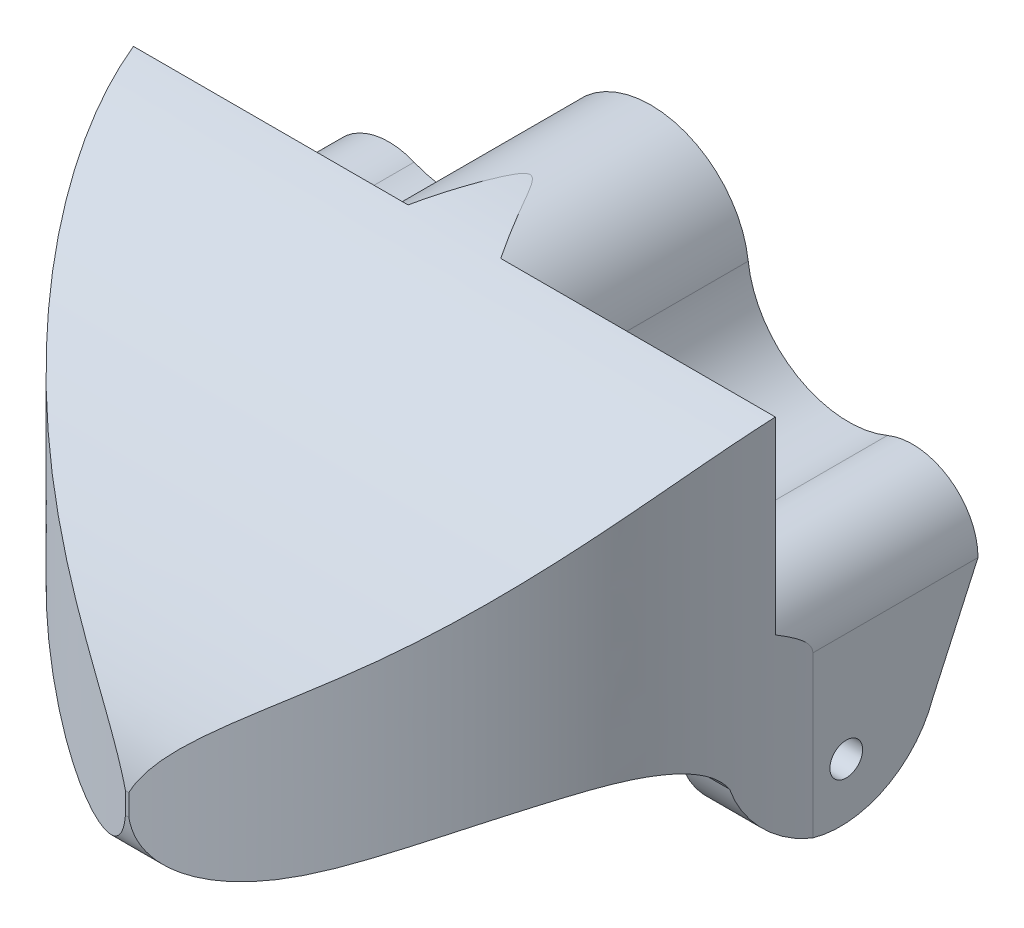
from build123d import *

# Parameters (mm, degrees)
SKETCH1_W                = 50
SKETCH1_H                = 35
BOSS_EXTRUDE1_DEPTH      = 40
CUT_EXTRUDE3_DEPTH       = 15
CUT_EXTRUDE6_DEPTH       = 51.311529494
CUT_EXTRUDE6_DEPTH_BACK  = 51.311529494
CUT_EXTRUDE8_DEPTH       = 51.292408862
CUT_EXTRUDE8_DEPTH_BACK  = 51.292408862
SKETCH6_W                = 40
SKETCH6_H                = 12.54309885
CUT_EXTRUDE9_DEPTH       = 25
SKETCH7_R                = 1.25
CUT_EXTRUDE10_DEPTH      = 51.292408862
CUT_EXTRUDE10_DEPTH_BACK = 51.292408862


with BuildPart() as part:
    # Sketch1 → Boss-Extrude1 (new body)
    with BuildSketch(Plane.XY):
        Rectangle(SKETCH1_W, SKETCH1_H)
    extrude(amount=BOSS_EXTRUDE1_DEPTH)

    # Sketch3 → Cut-Extrude3 (cut)
    with BuildSketch(Plane.XY):
        with BuildLine():
            ThreePointArc((18.080023646, 4.616675297), (22.774898037, 4.159319762), (25, 0))
            Line((25, 0), (25, 17.5))
            Line((25, 17.5), (20.265083079, 17.5))
            ThreePointArc((20.265083079, 17.5), (22.164558634, 14.89755515), (22.836723839, 11.746536186))
            ThreePointArc((22.836723839, 11.746536186), (21.538401387, 7.461063254), (18.080023646, 4.616675297))
        make_face()
        with BuildLine():
            ThreePointArc((9.964651512, 17.5), (7.890776302, 14.474095131), (7.447285057, 10.832615462))
            ThreePointArc((7.447285057, 10.832615462), (11.217729841, 5.080248753), (18.080023646, 4.616675297))
            ThreePointArc((18.080023646, 4.616675297), (21.538401387, 7.461063254), (22.836723839, 11.746536186))
            ThreePointArc((22.836723839, 11.746536186), (22.164558634, 14.89755515), (20.265083079, 17.5))
            Line((20.265083079, 17.5), (9.964651512, 17.5))
        make_face()
        with BuildLine():
            ThreePointArc((20.265083079, 17.5), (15.114867296, 19.46839273), (9.964651512, 17.5))
            Line((9.964651512, 17.5), (20.265083079, 17.5))
        make_face()
        with BuildLine():
            ThreePointArc((-7.393010752, 11.746536186), (-7.406591271, 11.28877073), (-7.447285061, 10.832615429))
            ThreePointArc((-7.447285061, 10.832615429), (-1.7e-08, 17.444952642), (7.447285057, 10.832615462))
            ThreePointArc((7.447285057, 10.832615462), (7.890776302, 14.474095131), (9.964651512, 17.5))
            Line((9.964651512, 17.5), (-9.964651512, 17.5))
            ThreePointArc((-9.964651512, 17.5), (-8.065175957, 14.89755515), (-7.393010752, 11.746536186))
        make_face()
        with BuildLine():
            ThreePointArc((-20.265083079, 17.5), (-22.728002657, 10.455320307), (-18.080023619, 4.616675286))
            ThreePointArc((-18.080023619, 4.616675286), (-11.217729842, 5.080248753), (-7.447285061, 10.832615429))
            ThreePointArc((-7.447285061, 10.832615429), (-7.406591271, 11.28877073), (-7.393010752, 11.746536186))
            ThreePointArc((-7.393010752, 11.746536186), (-8.065175957, 14.89755515), (-9.964651512, 17.5))
            Line((-9.964651512, 17.5), (-20.265083079, 17.5))
        make_face()
        with BuildLine():
            ThreePointArc((-9.964651512, 17.5), (-15.114867296, 19.46839273), (-20.265083079, 17.5))
            Line((-20.265083079, 17.5), (-9.964651512, 17.5))
        make_face()
        with BuildLine():
            Line((-25, 17.5), (-25, 2.5e-08))
            ThreePointArc((-25, 2.5e-08), (-22.774898014, 4.159319778), (-18.080023619, 4.616675286))
            ThreePointArc((-18.080023619, 4.616675286), (-22.728002657, 10.455320307), (-20.265083079, 17.5))
            Line((-20.265083079, 17.5), (-25, 17.5))
        make_face()
    extrude(amount=CUT_EXTRUDE3_DEPTH, mode=Mode.SUBTRACT)

    # Sketch4 → Cut-Extrude6 (cut, two sides)
    with BuildSketch(Plane(origin=(0, 0, 0), x_dir=(0, 0, -1), z_dir=(1, 0, 0))) as cut_extrude6_sk:
        with BuildLine():
            add(Edge.make_bspline(
                [(-9.222271241, 17.444952642), (-10.649134008, 17.379362556), (-16.532124994, 16.800094175), (-24.99058992, 11.744877304), (-33.962260097, 3.205152878), (-39.211523546, -3.38022438), (-40, -7.980712731)],
                knots=[0.128951398, 0.128951398, 0.128951398, 0.128951398, 0.217673321, 0.497466286, 0.713557135, 1, 1, 1, 1], degree=3))
            Line((-9.222271241, 17.444952642), (-40, 17.444952642))
            Line((-40, 17.444952642), (-40, -7.980712731))
        make_face()
        with BuildLine():
            Line((0, 0), (-3.44001081, -7.539638425))
            ThreePointArc((-3.44001081, -7.539638425), (-10.74719823, -12.539419504), (-17.727021343, -7.091955125))
            add(Edge.make_bspline(
                [(-17.727021343, -7.091955125), (-18.502936425, -5.824551955), (-21.808604968, -4.479724911), (-27.869116221, -5.844724863), (-33.812288914, -9.39721757), (-39.72251086, -14.860797268), (-40, -9.623944384)],
                knots=[0.042605041, 0.042605041, 0.042605041, 0.042605041, 0.193253168, 0.379939411, 0.648785626, 0.970666237, 0.970666237, 0.970666237, 0.970666237], degree=3))
            Line((-40, -9.623944384), (-40, -17.5))
            Line((-40, -17.5), (0, -17.5))
            Line((0, -17.5), (0, 0))
        make_face()
    extrude(amount=CUT_EXTRUDE6_DEPTH, mode=Mode.SUBTRACT)
    extrude(cut_extrude6_sk.sketch, amount=-CUT_EXTRUDE6_DEPTH_BACK, mode=Mode.SUBTRACT)


with BuildPart() as cut_extrude6_kept_piece:
    # of the separate pieces the step leaves, the one the design keeps (cut_extrude6_pieces_kept)
    add(part.part.solids().sort_by_distance((-7.447285061, 10.832615429, 15))[0])

    # Sketch5 → Cut-Extrude8 (cut, two sides)
    with BuildSketch(Plane(origin=(0, 0, 0), x_dir=(1, 0, 0), z_dir=(0, 1, 0))) as cut_extrude8_sk:
        with BuildLine():
            add(Edge.make_bspline(
                [(-25, -12.617742903), (-21.837163113, -31.626777816), (0, -40.051194025)],
                knots=[0, 0, 0, 1, 1, 1], degree=2))
            Line((0, -40.051194025), (-25, -40))
            Line((-25, -40), (-25, -12.617742903))
        make_face()
        with BuildLine():
            Line((25, -40), (25, -12.617742903))
            add(Edge.make_bspline(
                [(25, -12.617742903), (21.837163113, -31.626777816), (0, -40.051194025)],
                knots=[0, 0, 0, 1, 1, 1], degree=2))
            Line((0, -40.051194025), (25, -40))
        make_face()
    extrude(amount=CUT_EXTRUDE8_DEPTH, mode=Mode.SUBTRACT)
    extrude(cut_extrude8_sk.sketch, amount=-CUT_EXTRUDE8_DEPTH_BACK, mode=Mode.SUBTRACT)

    # Sketch6 → Cut-Extrude9 (cut)
    with BuildSketch(Plane.XY):
        with Locations((0, -6.271549425)):
            Rectangle(SKETCH6_W, SKETCH6_H)
    extrude(amount=CUT_EXTRUDE9_DEPTH, mode=Mode.SUBTRACT)

    # Sketch7 → Cut-Extrude10 (cut, two sides)
    with BuildSketch(Plane(origin=(0, 0, 0), x_dir=(0, 0, -1), z_dir=(1, 0, 0))) as cut_extrude10_sk:
        with Locations((-10.065545273, -8.297943519)):
            Circle(SKETCH7_R)
    extrude(amount=CUT_EXTRUDE10_DEPTH, mode=Mode.SUBTRACT)
    extrude(cut_extrude10_sk.sketch, amount=-CUT_EXTRUDE10_DEPTH_BACK, mode=Mode.SUBTRACT)


solid = cut_extrude6_kept_piece.part
